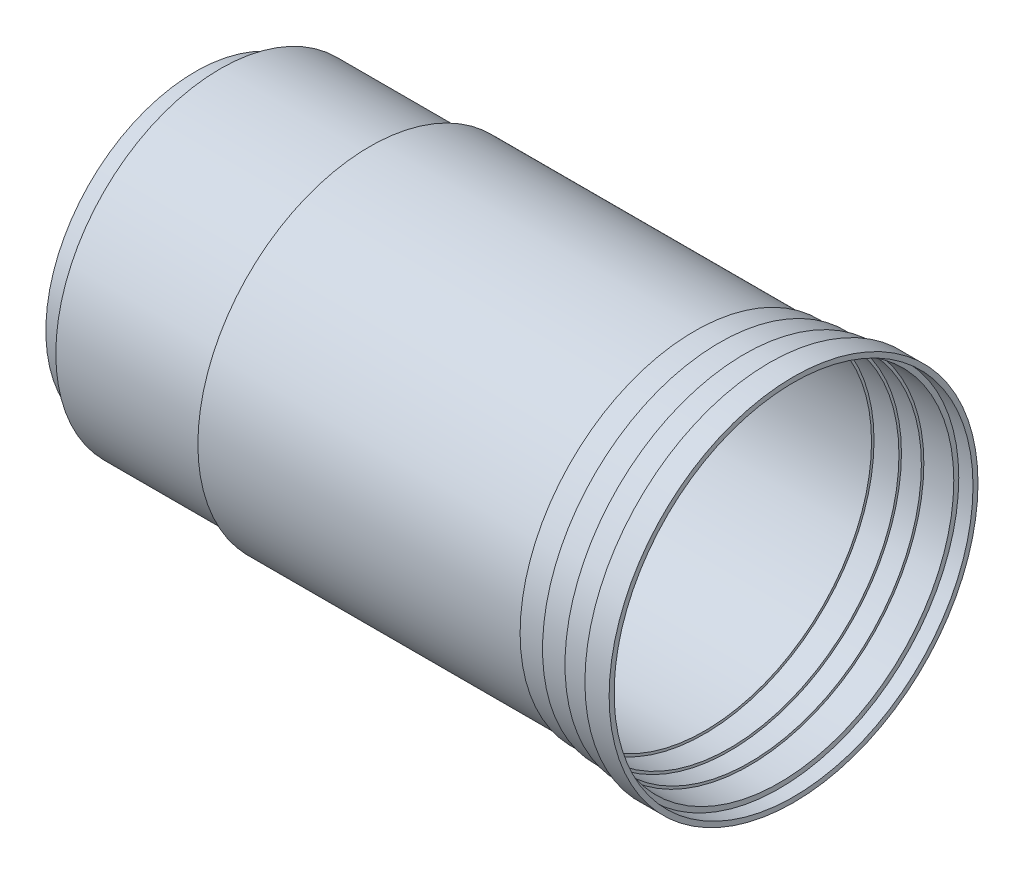
from build123d import *


with BuildPart() as part:
    # Esquisse1 → Révolution1 (revolve)
    with BuildSketch(Plane.XY):
        Polygon((-120, 0), (-120, 30), (-115, 30), (-115, 33), (-85, 33), (-85, 34.5), (-19.857262544, 34.5), (-19.857262544, 35), (-14.857262544, 35), (-14.857262544, 35.5), (-9.857262544, 35.5), (-9.857262544, 36), (-4.857262544, 36), (-4.857262544, 37), (0, 37), (0, 36), (-2.857262544, 36), (-2.857262544, 35), (-8.863097737, 35), (-8.863097737, 34.5), (-12.857262544, 34.5), (-12.857262544, 34), (-17.857262544, 34), (-17.857262544, 33.5), (-84, 33.5), (-84, 32), (-114, 32), (-114, 29), (-119, 29), (-119, 0), align=None)
    revolve(axis=Axis((0, 0, 0), (-1, 0, 0)))


solid = part.part
